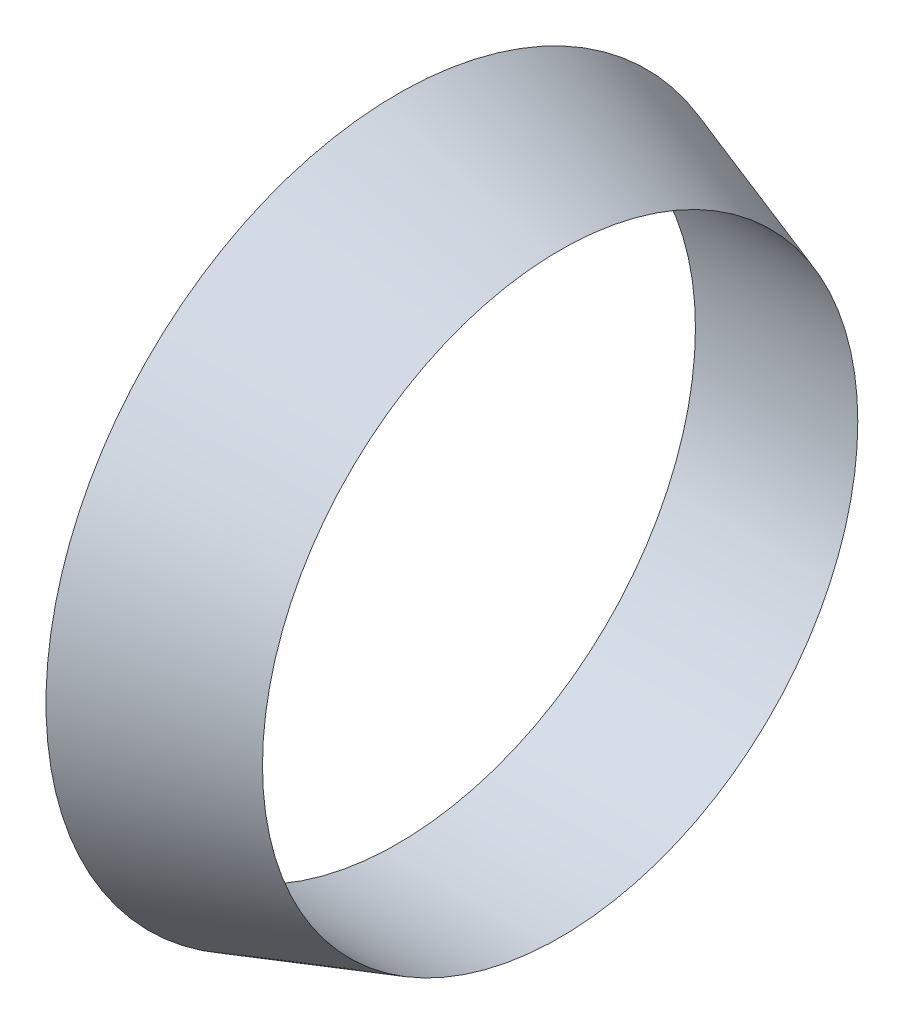
from build123d import *

# Parameters (mm, degrees)
SKETCH1_R          = 65
SKETCH2_R          = 55
SKETCH3_R          = 55
CUT_EXTRUDE1_DEPTH = 31.0000001


with BuildPart() as part:
    # Sketch1 → Loft1 section 0
    with BuildSketch(Plane(origin=(0, 0, 0), x_dir=(0, 0, -1), z_dir=(1, 0, 0))):
        Circle(SKETCH1_R)
    # Sketch2 → Loft1 section 1
    with BuildSketch(Plane(origin=(30, 0, 0), x_dir=(0, 0, -1), z_dir=(1, 0, 0))):
        Circle(SKETCH2_R)
    loft()

    # Sketch3 → Cut-Extrude1 (cut, through all)
    with BuildSketch(Plane(origin=(30, 0, 0), x_dir=(0, 0, -1), z_dir=(1, 0, 0))):
        Circle(SKETCH3_R)
    extrude(amount=-CUT_EXTRUDE1_DEPTH, mode=Mode.SUBTRACT)


solid = part.part
